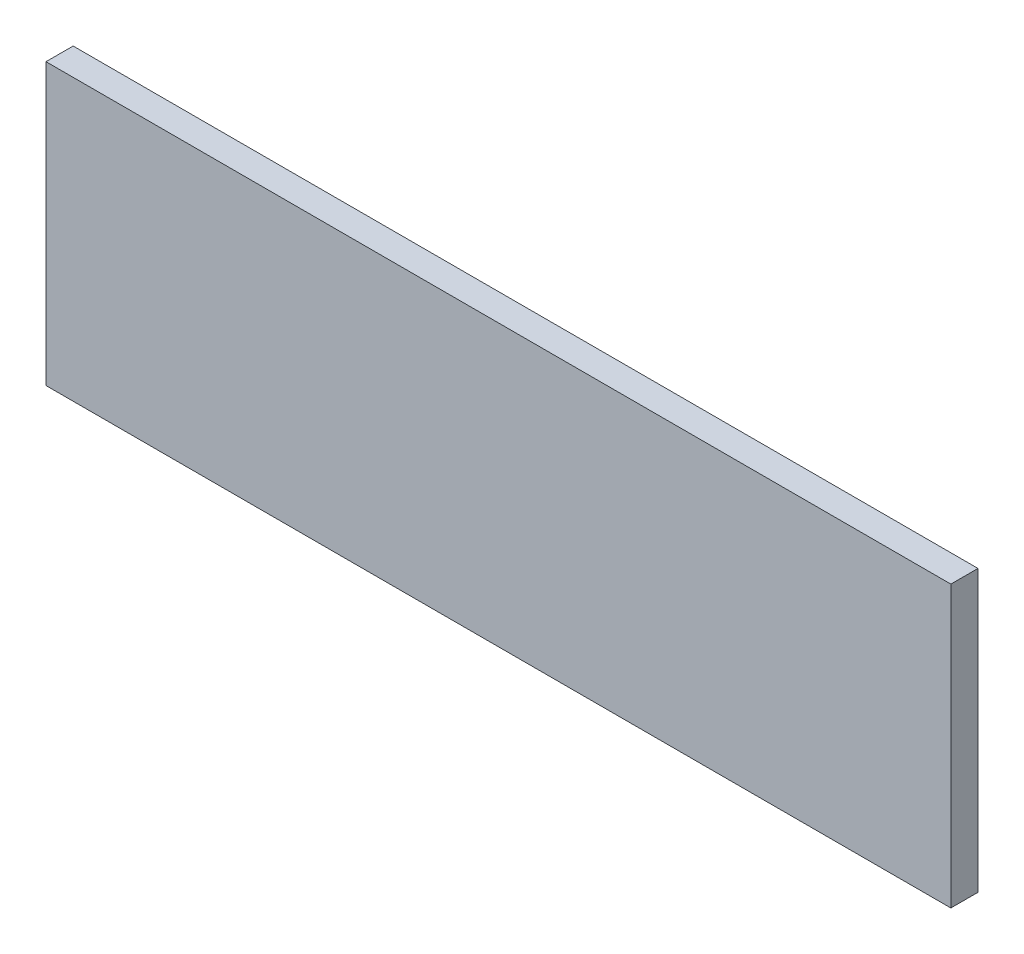
from build123d import *

# Parameters (mm, degrees)
ESQUISSE1_W        = 100
ESQUISSE1_H        = 31
BOSS_EXTRU_1_DEPTH = 3


with BuildPart() as part:
    # Esquisse1 → Boss.-Extru.1 (new body)
    with BuildSketch(Plane.XY):
        Rectangle(ESQUISSE1_W, ESQUISSE1_H)
    extrude(amount=BOSS_EXTRU_1_DEPTH)


solid = part.part
